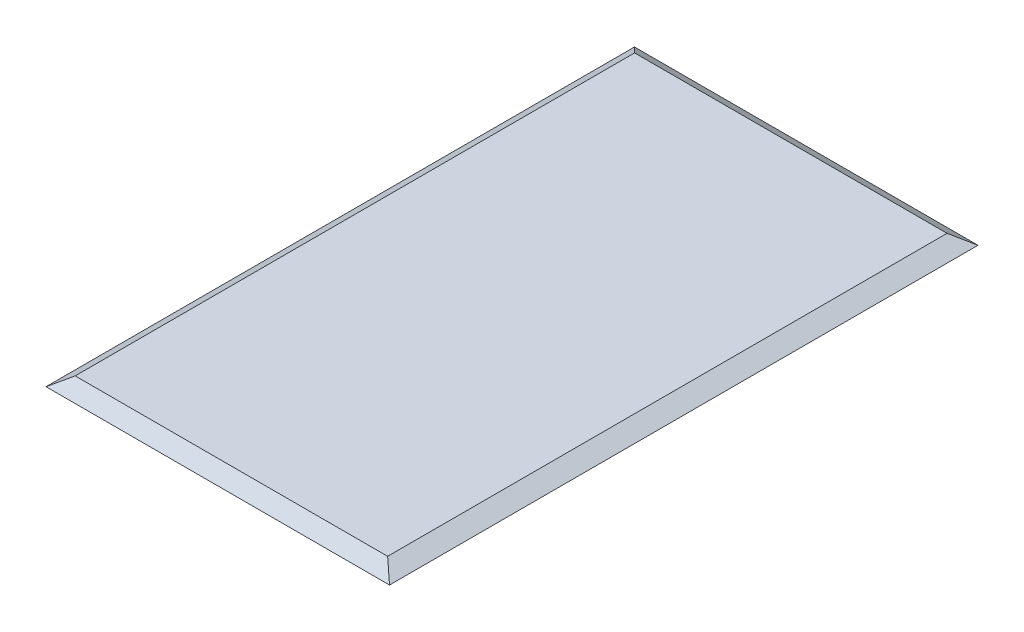
from build123d import *

# Parameters (mm, degrees)
SKETCH_1_W          = 3298.067470497
SKETCH_1_H          = 5650
EXTRUDE_1_DEPTH     = 90
SKETCH_2_OUTSIDE_W  = 4608.621
SKETCH_2_OUTSIDE_H  = 1400.554
CUT_EXTRUDE_1_DEPTH = 5651
SKETCH_3_OUTSIDE_W  = 6960.554
SKETCH_3_OUTSIDE_H  = 1400.554
CUT_EXTRUDE_4_DEPTH = 3299.067470497
SKETCH_4_W          = 3000
SKETCH_4_H          = 5390
CUT_EXTRUDE_5_DEPTH = 60


with BuildPart() as part:
    # Эскиз1 → Бобышка-Вытянуть1 (new body)
    with BuildSketch(Plane(origin=(0, 0, 0), x_dir=(1, 0, 0), z_dir=(0, 1, 0))):
        with Locations((1649.033735249, 2825)):
            Rectangle(SKETCH_1_W, SKETCH_1_H)
    extrude(amount=EXTRUDE_1_DEPTH)

    # Эскиз2 outside → Вырез-Вытянуть1 (cut, through all)
    with BuildSketch(Plane.XY):
        with Locations((1649.0335, 45)):
            Rectangle(SKETCH_2_OUTSIDE_W, SKETCH_2_OUTSIDE_H)
        Polygon((0, 0), (140, 90), (3140, 90), (3298.067470497, 0), align=None, mode=Mode.SUBTRACT)
    extrude(amount=-CUT_EXTRUDE_1_DEPTH, mode=Mode.SUBTRACT)

    # Эскиз3 outside → Вырез-Вытянуть4 (cut, through all)
    with BuildSketch(Plane(origin=(0, 0, 0), x_dir=(0, 0, -1), z_dir=(1, 0, 0))):
        with Locations((2825, 45)):
            Rectangle(SKETCH_3_OUTSIDE_W, SKETCH_3_OUTSIDE_H)
        Polygon((0, 0), (140, 90), (5510.895976381, 90), (5650, 0), align=None, mode=Mode.SUBTRACT)
    extrude(amount=CUT_EXTRUDE_4_DEPTH, mode=Mode.SUBTRACT)

    # Эскиз4 → Вырез-Вытянуть5 (cut)
    with BuildSketch(Plane.XZ):
        with Locations((1640, -2835)):
            Rectangle(SKETCH_4_W, SKETCH_4_H)
    extrude(amount=-CUT_EXTRUDE_5_DEPTH, mode=Mode.SUBTRACT)


solid = part.part
